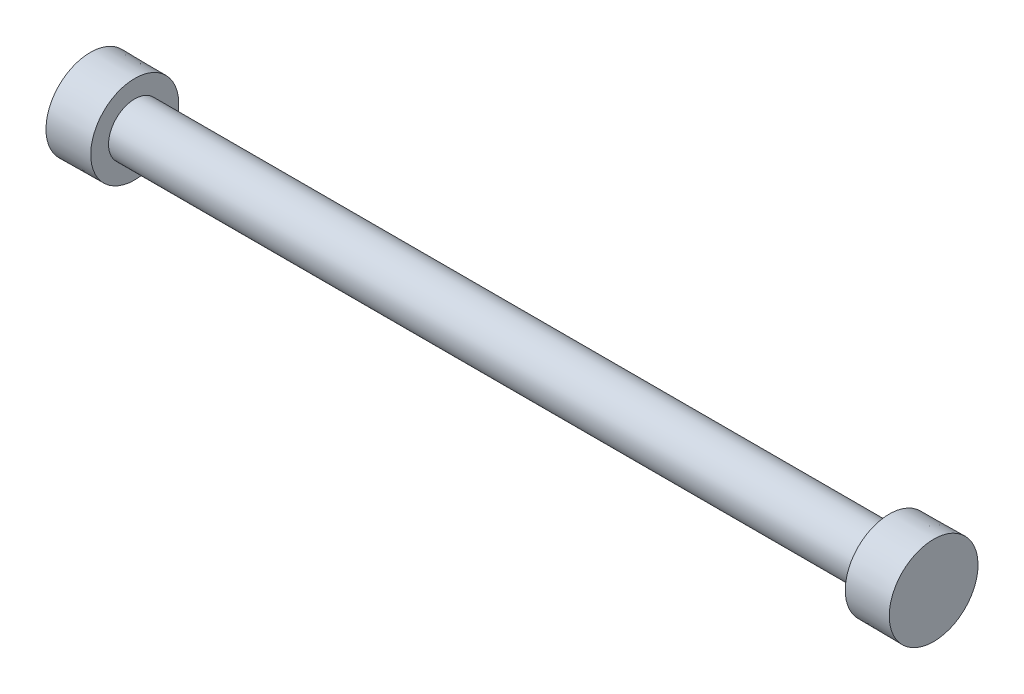
from build123d import *


with BuildPart() as part:
    # Sketch1 → Revolve1 (revolve)
    with BuildSketch(Plane.XY):
        Polygon((-33.114393489, 0.533154025), (-33.114393489, 5.533154025), (-28.114583333, 5.489583333), (-28.114583333, 3.489583333), (56.885416667, 3.489583333), (56.885416667, 5.489583333), (61.885226823, 5.533154025), (61.885226823, 0.533154025), align=None)
    revolve(axis=Axis((-33.114393489, 0.533154025, 0), (1, 0, 0)))


solid = part.part
